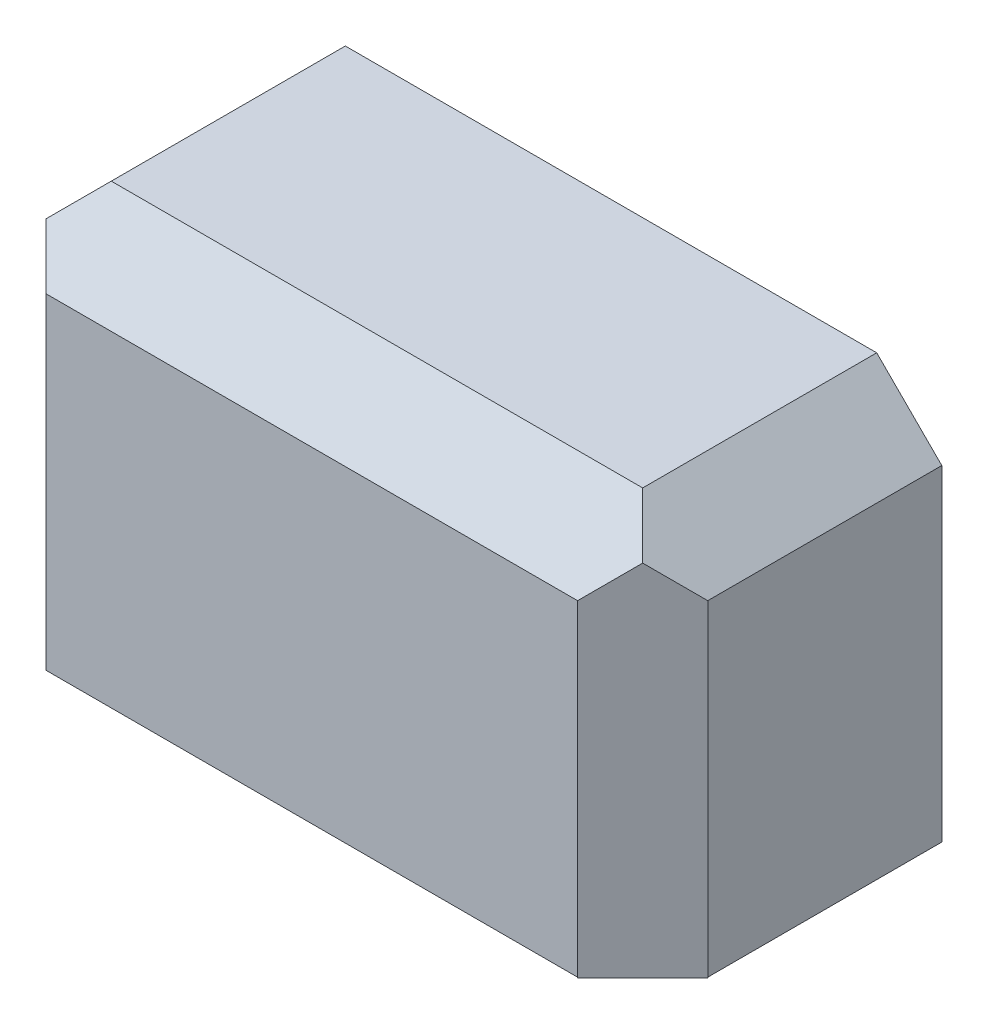
from build123d import *

# Parameters (mm, degrees)
BOSS_EXTRUDE3_DEPTH      = 165.1
CUT_EXTRUDE1_DEPTH       = 160.3375
BOSS_EXTRUDE4_DEPTH      = 4.7625
CUT_EXTRUDE2_DEPTH       = 11.176
CUT_EXTRUDE2_DEPTH_BACK  = 387.2865
BOSS_EXTRUDE5_DEPTH      = 365.125
CUT_EXTRUDE3_DEPTH       = 365.125
CUT_EXTRUDE4_DEPTH       = 365.125
BOSS_EXTRUDE6_DEPTH      = 1.27
BOSS_EXTRUDE6_DEPTH_BACK = 216.027
CUT_EXTRUDE5_DEPTH       = 398.907
CUT_EXTRUDE7_DEPTH       = 398.907
CUT_EXTRUDE8_DEPTH       = 216.281
BOSS_EXTRUDE7_DEPTH      = 216.281
CUT_EXTRUDE9_DEPTH       = 216.281
CUT_EXTRUDE10_DEPTH      = 2540


with BuildPart() as part:
    # Sketch13 → Boss-Extrude3 (new body)
    with BuildSketch(Plane.XY):
        Polygon((0, 0), (0, 179.978975516), (35.921024484, 215.9), (329.203975516, 215.9), (365.125, 179.978975516), (365.125, 0), align=None)
    extrude(amount=BOSS_EXTRUDE3_DEPTH)

    # Sketch14 → Cut-Extrude1 (cut)
    with BuildSketch(Plane.XY.offset(165.1)):
        Polygon((4.7625, 0), (4.7625, 177.794773237), (38.105226763, 211.1375), (327.231283425, 211.1375), (360.3625, 178.006283425), (360.3625, 0), align=None)
    extrude(amount=-CUT_EXTRUDE1_DEPTH, mode=Mode.SUBTRACT)

    # Sketch15 → Boss-Extrude4 (add)
    with BuildSketch(Plane.XY.offset(165.1)):
        Polygon((0, 0), (0, 179.978975516), (35.921024484, 215.9), (329.203975516, 215.9), (365.125, 179.978975516), (365.125, 0), align=None)
    extrude(amount=-BOSS_EXTRUDE4_DEPTH)

    # Sketch16 → Cut-Extrude2 (cut, two sides)
    with BuildSketch(Plane(origin=(365.125, 0, 0), x_dir=(0, 0, -1), z_dir=(1, 0, 0))) as cut_extrude2_sk:
        Polygon((-165.1, 179.978975516), (-129.178975516, 215.9), (-165.1, 215.9), align=None)
    extrude(amount=CUT_EXTRUDE2_DEPTH, mode=Mode.SUBTRACT)
    extrude(cut_extrude2_sk.sketch, amount=-CUT_EXTRUDE2_DEPTH_BACK, mode=Mode.SUBTRACT)

    # Sketch17 → Boss-Extrude5 (add)
    with BuildSketch(Plane(origin=(365.125, 0, 0), x_dir=(0, 0, -1), z_dir=(1, 0, 0))):
        Polygon((-165.1, 179.978975516), (-129.178975516, 215.9), (-125.81137947, 212.532403955), (-161.732403955, 176.61137947), align=None)
    extrude(amount=-BOSS_EXTRUDE5_DEPTH)

    # Sketch18 → Cut-Extrude3 (cut)
    with BuildSketch(Plane(origin=(0, 0, 0), x_dir=(-1, 0, 0), z_dir=(0, 0, -1))):
        Polygon((-365.125, 179.978975516), (-329.203975516, 215.9), (-365.125, 215.9), align=None)
        Polygon((-35.921024484, 215.9), (0, 215.9), (0, 179.978975516), align=None)
    extrude(amount=-CUT_EXTRUDE3_DEPTH, mode=Mode.SUBTRACT)

    # Sketch19 → Cut-Extrude4 (cut)
    with BuildSketch(Plane(origin=(0, 215.9, 0), x_dir=(1, 0, 0), z_dir=(0, 1, 0))):
        Polygon((0, -129.178975516), (35.921024484, -165.1), (0, -165.1), align=None)
    extrude(amount=-CUT_EXTRUDE4_DEPTH, mode=Mode.SUBTRACT)

    # Sketch20 → Boss-Extrude6 (add, two sides)
    with BuildSketch(Plane(origin=(0, 215.9, 0), x_dir=(1, 0, 0), z_dir=(0, 1, 0))) as boss_extrude6_sk:
        Polygon((0, -129.178975516), (35.921024484, -165.1), (39.28862053, -161.732403955), (3.367596045, -125.81137947), align=None)
    extrude(amount=BOSS_EXTRUDE6_DEPTH)
    extrude(boss_extrude6_sk.sketch, amount=-BOSS_EXTRUDE6_DEPTH_BACK)

    # Sketch21 → Cut-Extrude5 (cut)
    with BuildSketch(Plane(origin=(365.125, 0, 0), x_dir=(0, 0, -1), z_dir=(1, 0, 0))):
        Polygon((-165.1, 179.978975516), (-129.178975516, 215.9), (-125.060291361, 215.9), (-125.060291361, 220.601518186), (-193.24025866, 220.601518186), (-185.719207112, 179.978975516), align=None)
    extrude(amount=-CUT_EXTRUDE5_DEPTH, mode=Mode.SUBTRACT)

    # Sketch22 → Cut-Extrude7 (cut)
    with BuildSketch(Plane(origin=(0, 0, 0), x_dir=(-1, 0, 0), z_dir=(0, 0, -1))):
        Polygon((0, 179.978975516), (-35.921024484, 215.9), (-15.545950188, 236.275074296), (20.375074296, 200.354049812), align=None)
    extrude(amount=-CUT_EXTRUDE7_DEPTH, mode=Mode.SUBTRACT)

    # Sketch24 → Cut-Extrude8 (cut)
    with BuildSketch(Plane(origin=(0, 215.9, 0), x_dir=(1, 0, 0), z_dir=(0, 1, 0))):
        Polygon((329.203975516, -165.1), (365.125, -129.178975516), (387.404902752, -151.458878267), (351.483878267, -187.379902752), align=None)
    extrude(amount=-CUT_EXTRUDE8_DEPTH, mode=Mode.SUBTRACT)

    # Sketch25 → Boss-Extrude7 (add)
    with BuildSketch(Plane(origin=(0, 215.9, 0), x_dir=(1, 0, 0), z_dir=(0, 1, 0))):
        Polygon((329.203975516, -165.1), (365.125, -129.178975516), (361.757403955, -125.81137947), (325.83637947, -161.732403955), align=None)
    extrude(amount=-BOSS_EXTRUDE7_DEPTH)

    # Sketch26 → Cut-Extrude9 (cut)
    with BuildSketch(Plane(origin=(0, 0, 0), x_dir=(-1, 0, 0), z_dir=(0, 0, -1))):
        Polygon((-365.125, 179.978975516), (-329.203975516, 215.9), (-357.158082667, 243.854107151), (-393.079107151, 207.933082667), align=None)
    extrude(amount=-CUT_EXTRUDE9_DEPTH, mode=Mode.SUBTRACT)

    # Sketch27 → Cut-Extrude10 (cut)
    with BuildSketch(Plane.ZY):
        Polygon((129.178975516, 215.9), (165.1, 179.978975516), (185.560673149, 200.439648664), (149.639648664, 236.360673149), align=None)
    extrude(amount=-CUT_EXTRUDE10_DEPTH, mode=Mode.SUBTRACT)


solid = part.part
